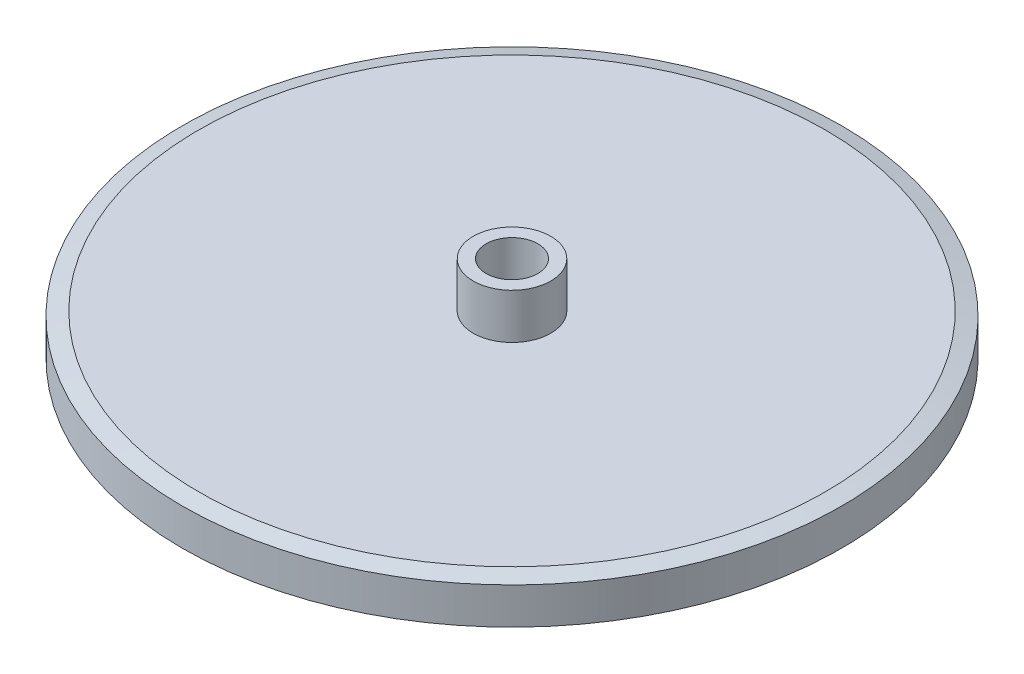
from build123d import *

# Parameters (mm, degrees)
CHAMFER_1_SIZE           = 1.25
CHAMFER_1_SIZE2          = 0.334936491
SKETCH_2_R               = 2
CUT_EXTRUDE_3_DEPTH      = 1
CUT_EXTRUDE_3_DEPTH_BACK = 8
CHAMFER_2_SIZE           = 1.25
CHAMFER_2_SIZE2          = 0.334936491


with BuildPart() as part:
    # Эскиз1 → Повернуть2 (revolve)
    with BuildSketch(Plane.XY):
        Polygon((0, 0), (25.5, 0), (25.5, 3.5), (3, 3.5), (3, 7), (0, 7), align=None)
    revolve(axis=Axis((0, 7, 0), (0, -1, 0)))

    # Фаска1
    chamfer_1_edges = [part.edges().sort_by_distance(p)[0] for p in [
        (-25.5, 3.5, 0),
    ]]
    chamfer_1_side = [part.faces().sort_by_distance(p)[0] for p in [
        (-24.778751083, 3.5, 0),
    ]]
    chamfer(chamfer_1_edges, length=CHAMFER_1_SIZE, length2=CHAMFER_1_SIZE2, reference=chamfer_1_side[0])

    # Эскиз2 → Вырез-Вытянуть3 (cut, two sides)
    with BuildSketch(Plane(origin=(0, 0, 0), x_dir=(-1, 0, 0), z_dir=(0, -1, 0))) as cut_extrude_3_sk:
        Circle(SKETCH_2_R)
    extrude(amount=CUT_EXTRUDE_3_DEPTH, mode=Mode.SUBTRACT)
    extrude(cut_extrude_3_sk.sketch, amount=-CUT_EXTRUDE_3_DEPTH_BACK, mode=Mode.SUBTRACT)

    # Фаска2
    chamfer_2_edges = [part.edges().sort_by_distance(p)[0] for p in [
        (-25.5, 0, 0),
    ]]
    chamfer_2_side = [part.faces().sort_by_distance(p)[0] for p in [
        (-24.778751083, 0, 0),
    ]]
    chamfer(chamfer_2_edges, length=CHAMFER_2_SIZE, length2=CHAMFER_2_SIZE2, reference=chamfer_2_side[0])


solid = part.part
